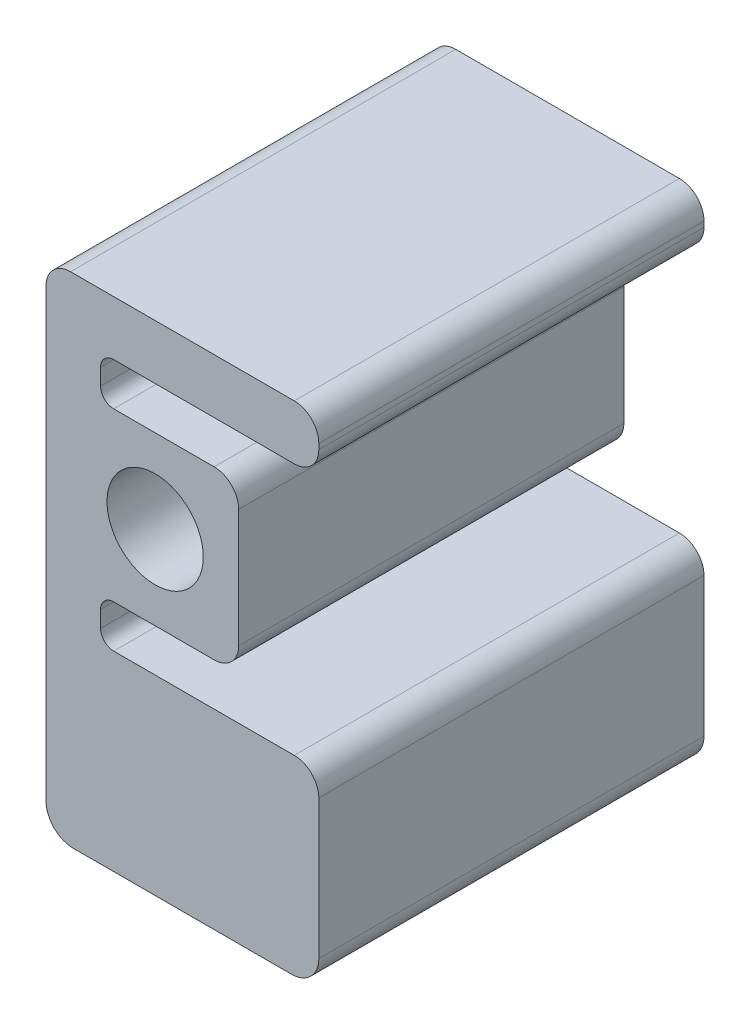
from build123d import *

# Parameters (mm, degrees)
SKETCH1_R           = 11.2
BOSS_EXTRUDE1_DEPTH = 89.651758212


with BuildPart() as part:
    # Sketch1 → Boss-Extrude1 (new body)
    with BuildSketch(Plane.XY):
        with BuildLine():
            Line((-25.4, -67.479999962), (-25.4, 36.365))
            ThreePointArc((-25.4, 36.365), (-23.726115254, 40.406115254), (-19.685, 42.08))
            Line((-19.685, 42.08), (32.385, 42.08))
            ThreePointArc((32.385, 42.08), (36.426115254, 40.406115254), (38.1, 36.365))
            Line((38.1, 36.365), (38.1, 35.095))
            ThreePointArc((38.1, 35.095), (36.426115254, 31.053884746), (32.385, 29.38))
            Line((32.385, 29.38), (-9.652, 29.38))
            ThreePointArc((-9.652, 29.38), (-11.807261469, 28.487261469), (-12.7, 26.332))
            Line((-12.7, 26.332), (-12.7, 22.503))
            ThreePointArc((-12.7, 22.503), (-11.807261469, 20.347738531), (-9.652, 19.455))
            Line((-9.652, 19.455), (0, 19.455))
            Line((0, 19.455), (13.74, 19.455))
            ThreePointArc((13.74, 19.455), (17.781115254, 17.781115254), (19.455, 13.74))
            Line((19.455, 13.74), (19.455, 0))
            Line((19.455, 0), (19.455, -13.74))
            ThreePointArc((19.455, -13.74), (17.781115254, -17.781115254), (13.74, -19.455))
            Line((13.74, -19.455), (0, -19.455))
            Line((0, -19.455), (-9.652, -19.455))
            ThreePointArc((-9.652, -19.455), (-11.807261469, -20.347738531), (-12.7, -22.503))
            Line((-12.7, -22.503), (-12.7, -26.331999962))
            ThreePointArc((-12.7, -26.331999962), (-11.807261469, -28.487261431), (-9.652, -29.379999962))
            Line((-9.652, -29.379999962), (32.385, -29.379999962))
            ThreePointArc((32.385, -29.379999962), (36.426115254, -31.053884708), (38.1, -35.094999962))
            Line((38.1, -35.094999962), (38.1, -67.479999962))
            ThreePointArc((38.1, -67.479999962), (36.240128061, -71.970128023), (31.75, -73.829999962))
            Line((31.75, -73.829999962), (-19.05, -73.829999962))
            ThreePointArc((-19.05, -73.829999962), (-23.540128061, -71.970128023), (-25.4, -67.479999962))
        make_face()
        Circle(SKETCH1_R, mode=Mode.SUBTRACT)
    extrude(amount=BOSS_EXTRUDE1_DEPTH)


solid = part.part
